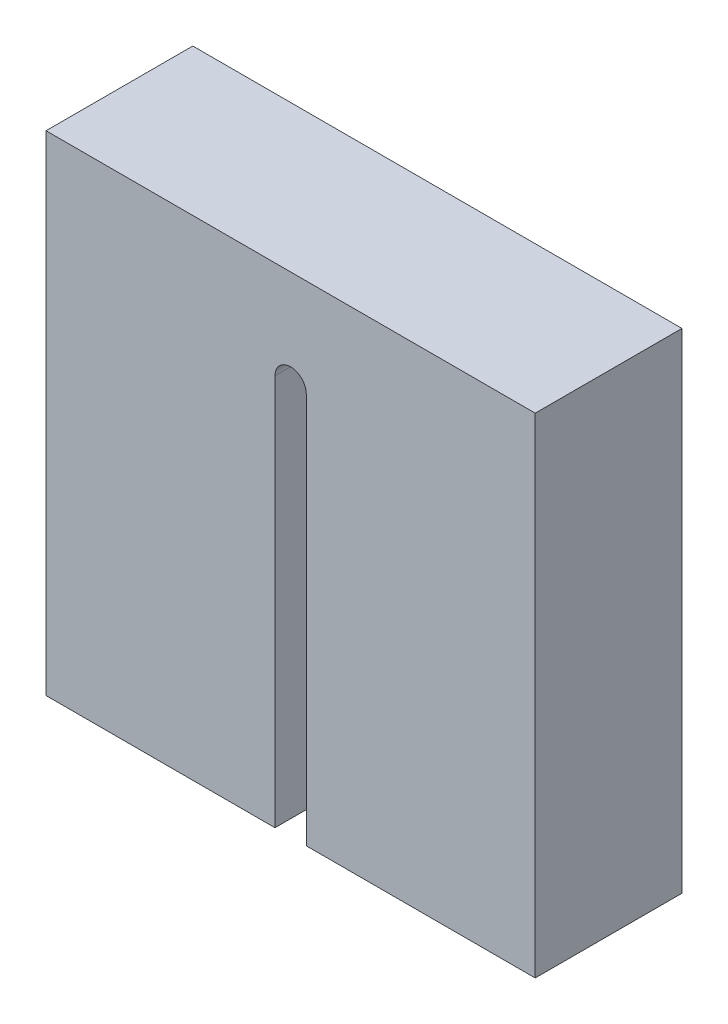
from build123d import *

# Parameters (mm, degrees)
EXTRUSION1_DEPTH = 15


with BuildPart() as part:
    # Esquisse1 → Extrusion1 (new body)
    with BuildSketch(Plane.XY):
        with BuildLine():
            Line((0, 0), (23.4, 0))
            Line((23.4, 0), (23.4, 40))
            ThreePointArc((23.4, 40), (25, 41.6), (26.6, 40))
            Line((26.6, 40), (26.6, 0))
            Line((26.6, 0), (50, 0))
            Line((50, 0), (50, 50))
            Line((50, 50), (0, 50))
            Line((0, 50), (0, 0))
        make_face()
    extrude(amount=EXTRUSION1_DEPTH)


solid = part.part
